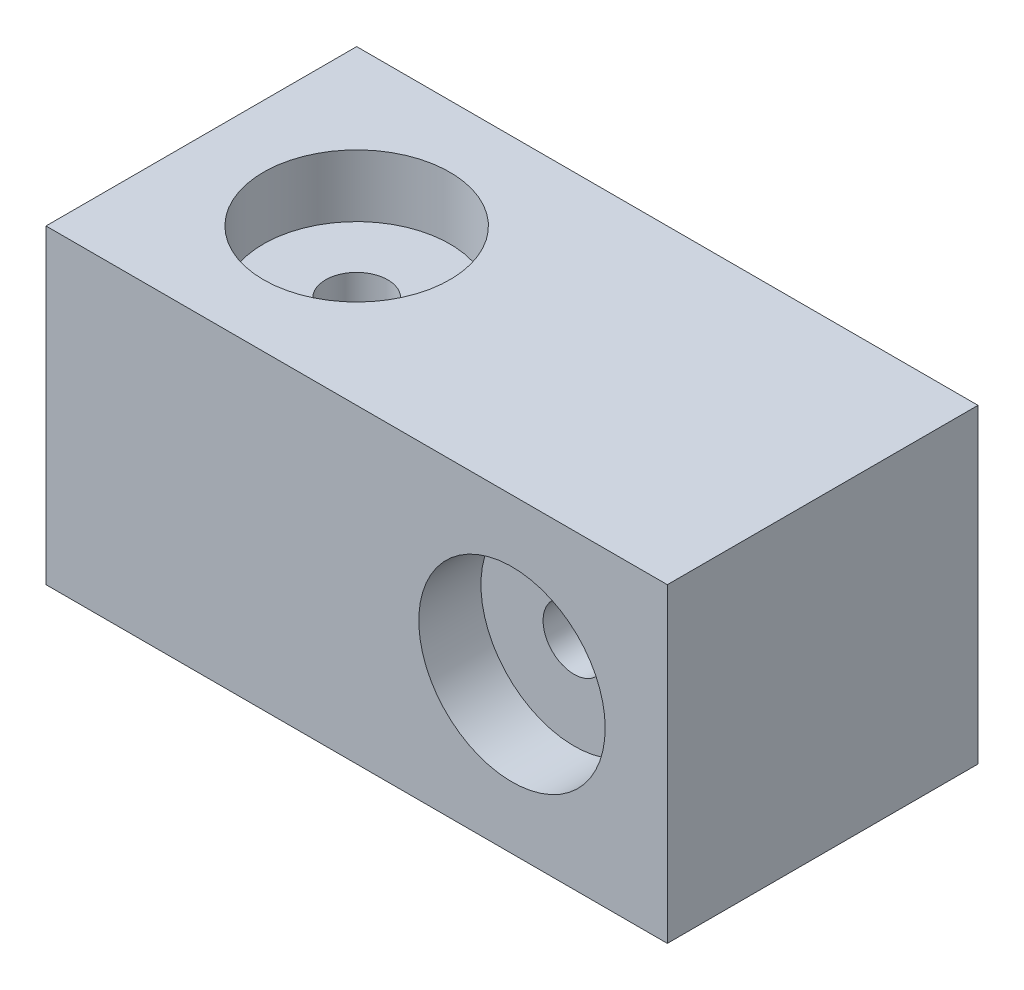
from build123d import *

# Parameters (mm, degrees)
SKETCH1_W           = 40
SKETCH1_H           = 20
BOX_DEPTH           = 20
SKETCH10_R          = 6
SIDE_CUT_DEPTH      = 4
CUT_EXTRUDE10_DEPTH = 20
CUT_EXTRUDE11_DEPTH = 4
CUT_EXTRUDE12_DEPTH = 20


with BuildPart() as part:
    # Sketch1 → Box (new body)
    with BuildSketch(Plane.XY):
        with Locations((-4.957264957, 0)):
            Rectangle(SKETCH1_W, SKETCH1_H)
    extrude(amount=BOX_DEPTH)

    # Sketch10 → Side Cut (cut)
    with BuildSketch(Plane.XY.offset(20)):
        with Locations((5.042735043, 0)):
            Circle(SKETCH10_R)
    extrude(amount=-SIDE_CUT_DEPTH, mode=Mode.SUBTRACT)

    # Sketch11 → Cut-Extrude10 (cut)
    with BuildSketch(Plane.XY.offset(20)):
        with BuildLine():
            ThreePointArc((7.042735043, 0), (6.456948605, 1.414213562), (5.042735043, 2))
            Line((5.042735043, 2), (5.042735043, -2))
            ThreePointArc((5.042735043, -2), (6.456948605, -1.414213562), (7.042735043, 0))
        make_face()
        with BuildLine():
            Line((5.042735043, -2), (5.042735043, 2))
            ThreePointArc((5.042735043, 2), (3.042735043, 0), (5.042735043, -2))
        make_face()
    extrude(amount=-CUT_EXTRUDE10_DEPTH, mode=Mode.SUBTRACT)

    # Sketch12 → Cut-Extrude11 (cut)
    with BuildSketch(Plane(origin=(0, 10, 0), x_dir=(1, 0, 0), z_dir=(0, 1, 0))):
        with BuildLine():
            ThreePointArc((-8.957264957, -10), (-14.957264957, -4), (-20.957264957, -10))
            Line((-20.957264957, -10), (-8.957264957, -10))
        make_face()
        with BuildLine():
            Line((-8.957264957, -10), (-20.957264957, -10))
            ThreePointArc((-20.957264957, -10), (-14.957264957, -16), (-8.957264957, -10))
        make_face()
    extrude(amount=-CUT_EXTRUDE11_DEPTH, mode=Mode.SUBTRACT)

    # Sketch13 → Cut-Extrude12 (cut)
    with BuildSketch(Plane(origin=(0, 10, 0), x_dir=(1, 0, 0), z_dir=(0, 1, 0))):
        with BuildLine():
            ThreePointArc((-12.957264957, -10), (-13.543051395, -8.585786438), (-14.957264957, -8))
            Line((-14.957264957, -8), (-14.957264957, -12))
            ThreePointArc((-14.957264957, -12), (-13.543051395, -11.414213562), (-12.957264957, -10))
        make_face()
        with BuildLine():
            Line((-14.957264957, -12), (-14.957264957, -8))
            ThreePointArc((-14.957264957, -8), (-16.957264957, -10), (-14.957264957, -12))
        make_face()
    extrude(amount=-CUT_EXTRUDE12_DEPTH, mode=Mode.SUBTRACT)


solid = part.part
